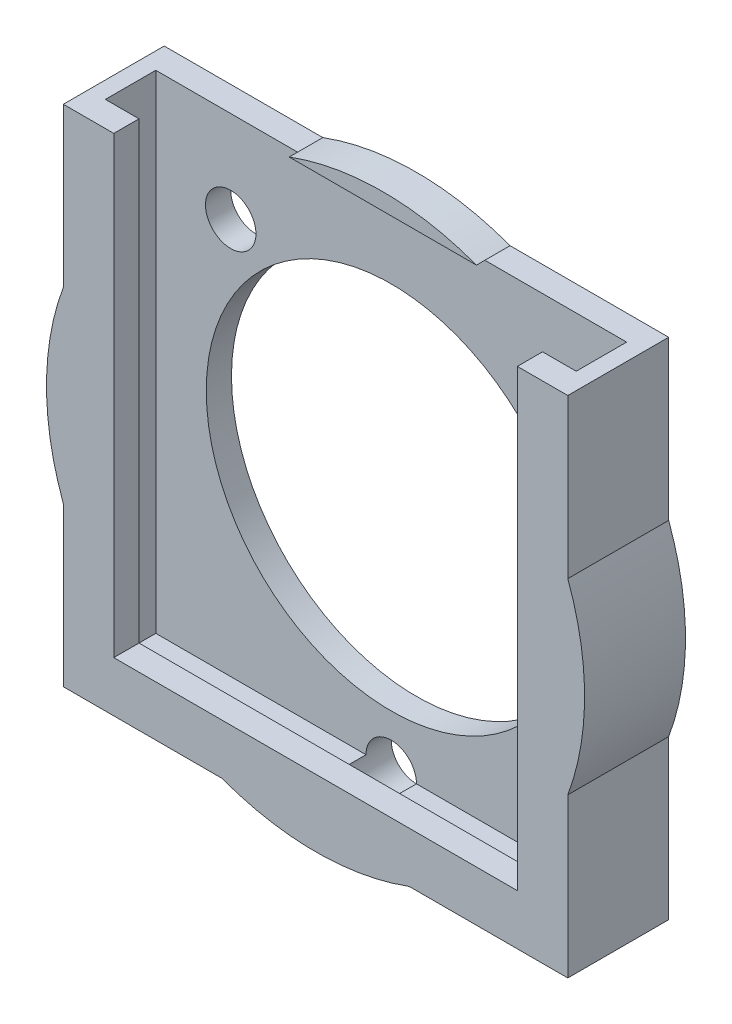
from build123d import *

# Parameters (mm, degrees)
SKETCH1_R           = 16
SKETCH1_W           = 30
SKETCH1_H           = 30
BOSS_EXTRUDE1_DEPTH = 6
SKETCH2_R           = 11
CUT_EXTRUDE1_DEPTH  = 10
SKETCH3_R           = 11
CUT_EXTRUDE2_DEPTH  = 4
CUT_EXTRUDE3_DEPTH  = 29
SKETCH5_W           = 8.432235637
SKETCH5_H           = 0.5
SKETCH5_W_2         = 2
CUT_EXTRUDE4_DEPTH  = 29
SKETCH6_R           = 1.5
CUT_EXTRUDE5_DEPTH  = 3


with BuildPart() as part:
    # Sketch1 → Boss-Extrude1 (new body)
    with BuildSketch(Plane.XY):
        Circle(SKETCH1_R)
        Rectangle(SKETCH1_W, SKETCH1_H)
    extrude(amount=BOSS_EXTRUDE1_DEPTH)

    # Sketch2 → Cut-Extrude1 (cut)
    with BuildSketch(Plane.XY.offset(6)):
        Circle(SKETCH2_R)
    extrude(amount=-CUT_EXTRUDE1_DEPTH, mode=Mode.SUBTRACT)

    # Sketch3 → Cut-Extrude2 (cut)
    with BuildSketch(Plane.XY.offset(6)):
        with BuildLine():
            Line((5.567764363, 15), (-5.567764363, 15))
            ThreePointArc((-5.567764363, 15), (-9.057264866, 13.189615353), (-12, 10.583005244))
            Line((-12, 10.583005244), (-12, -10.583005244))
            ThreePointArc((-12, -10.583005244), (-11.313708499, -11.313708499), (-10.583005244, -12))
            Line((-10.583005244, -12), (10.583005244, -12))
            ThreePointArc((10.583005244, -12), (11.313708499, -11.313708499), (12, -10.583005244))
            Line((12, -10.583005244), (12, 10.583005244))
            ThreePointArc((12, 10.583005244), (9.057264866, 13.189615353), (5.567764363, 15))
        make_face()
        Circle(SKETCH3_R, mode=Mode.SUBTRACT)
        with BuildLine():
            ThreePointArc((5.567764363, 15), (0, 16), (-5.567764363, 15))
            Line((-5.567764363, 15), (5.567764363, 15))
        make_face()
        with BuildLine():
            Line((-5.567764363, 15), (-12, 15))
            Line((-12, 15), (-12, 10.583005244))
            ThreePointArc((-12, 10.583005244), (-9.057264866, 13.189615353), (-5.567764363, 15))
        make_face()
        with BuildLine():
            Line((12, 15), (5.567764363, 15))
            ThreePointArc((5.567764363, 15), (9.057264866, 13.189615353), (12, 10.583005244))
            Line((12, 10.583005244), (12, 15))
        make_face()
        with BuildLine():
            Line((12, -12), (12, -10.583005244))
            ThreePointArc((12, -10.583005244), (11.313708499, -11.313708499), (10.583005244, -12))
            Line((10.583005244, -12), (12, -12))
        make_face()
        with BuildLine():
            ThreePointArc((-10.583005244, -12), (-11.313708499, -11.313708499), (-12, -10.583005244))
            Line((-12, -10.583005244), (-12, -12))
            Line((-12, -12), (-10.583005244, -12))
        make_face()
    extrude(amount=-CUT_EXTRUDE2_DEPTH, mode=Mode.SUBTRACT)

    # Sketch4 → Cut-Extrude3 (cut)
    with BuildSketch(Plane(origin=(0, 15, 0), x_dir=(1, 0, 0), z_dir=(0, 1, 0))):
        Polygon((-12, -2), (-14, -2), (-14, -4), (14, -4), (14, -2), (12, -2), align=None)
    extrude(amount=-CUT_EXTRUDE3_DEPTH, mode=Mode.SUBTRACT)

    # Sketch5 → Cut-Extrude4 (cut)
    with BuildSketch(Plane(origin=(0, 15, 0), x_dir=(1, 0, 0), z_dir=(0, 1, 0))):
        Polygon((-14, -2), (-14, -4), (14, -2), (14, -1.5), (-5.567764363, -1.5), (-5.567764363, -2), align=None)
        Polygon((14, -2), (-14, -4), (-12, -4), (-12, -4.5), (14, -4.5), align=None)
        with Locations((-9.783882182, -1.75)):
            Rectangle(SKETCH5_W, SKETCH5_H)
        with Locations((-13, -4.25)):
            Rectangle(SKETCH5_W_2, SKETCH5_H)
    extrude(amount=-CUT_EXTRUDE4_DEPTH, mode=Mode.SUBTRACT)

    # Sketch6 → Cut-Extrude5 (cut)
    with BuildSketch(Plane(origin=(0, 0, 0), x_dir=(-1, 0, 0), z_dir=(0, 0, -1))):
        with Locations((-9.545941546, 9.545941546)):
            Circle(SKETCH6_R)
        with Locations((9.545941546, 9.545941546)):
            Circle(SKETCH6_R)
        with Locations((0, -14)):
            Circle(SKETCH6_R)
    extrude(amount=-CUT_EXTRUDE5_DEPTH, mode=Mode.SUBTRACT)


solid = part.part
